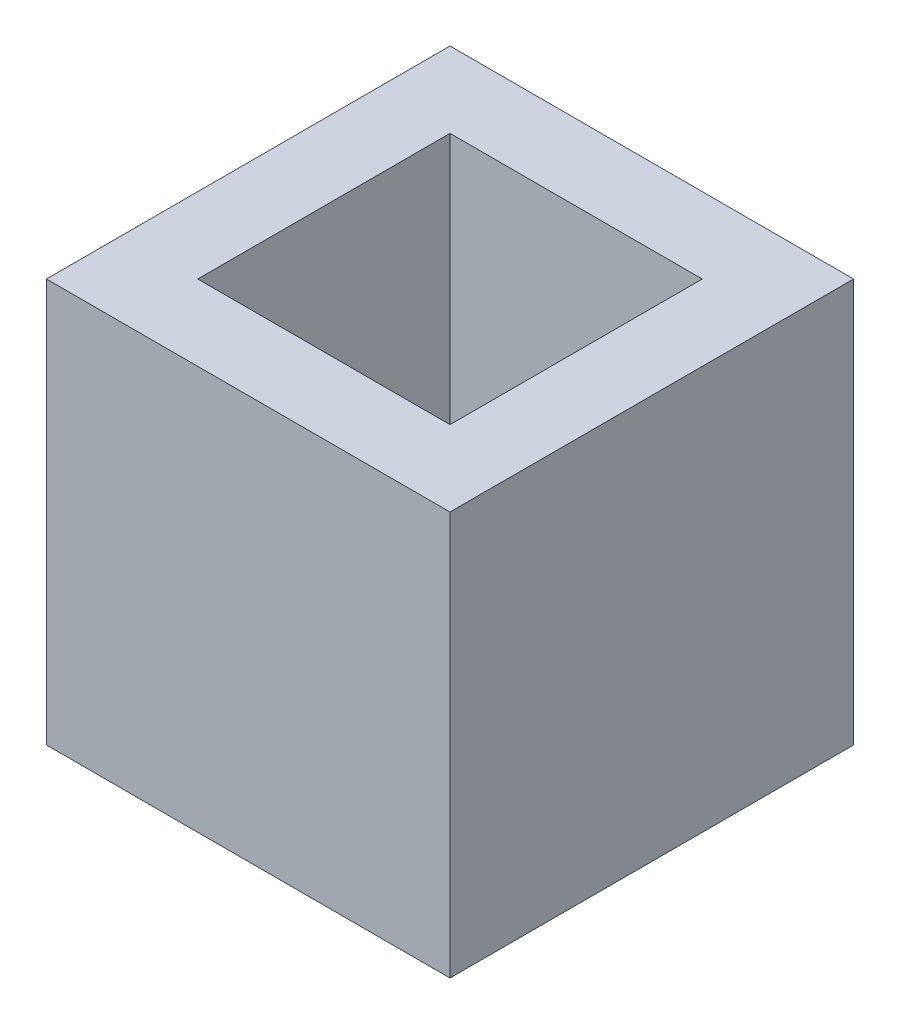
from build123d import *

# Parameters (mm, degrees)
SKETCH1_W           = 25.4
SKETCH1_H           = 25.4
BOSS_EXTRUDE1_DEPTH = 25.4
SKETCH2_W           = 15.875
SKETCH2_H           = 15.875
CUT_EXTRUDE1_DEPTH  = 26.4


with BuildPart() as part:
    # Sketch1 → Boss-Extrude1 (new body)
    with BuildSketch(Plane(origin=(0, 0, 0), x_dir=(1, 0, 0), z_dir=(0, 1, 0))):
        with Locations((12.7, 12.7)):
            Rectangle(SKETCH1_W, SKETCH1_H)
    extrude(amount=BOSS_EXTRUDE1_DEPTH)

    # Sketch2 → Cut-Extrude1 (cut, through all)
    with BuildSketch(Plane(origin=(0, 25.4, 0), x_dir=(1, 0, 0), z_dir=(0, 1, 0))):
        with Locations((12.7, 12.7)):
            Rectangle(SKETCH2_W, SKETCH2_H)
    extrude(amount=-CUT_EXTRUDE1_DEPTH, mode=Mode.SUBTRACT)


solid = part.part
